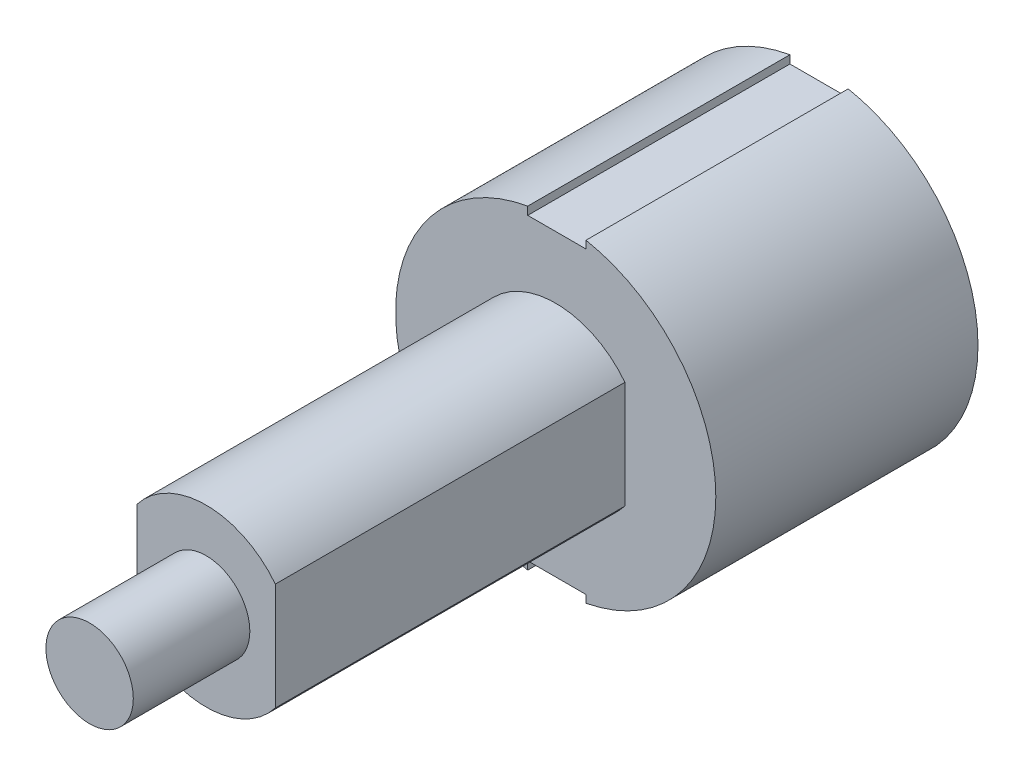
from build123d import *

# Parameters (mm, degrees)
SALIENTE_EXTRUIR4_DEPTH = 14.2875
CROQUIS1_6_R            = 2.38125
SALIENTE_EXTRUIR5_DEPTH = 33.3375
CROQUIS1_7_R            = 2.38125
SALIENTE_EXTRUIR6_DEPTH = 39.6875


with BuildPart() as part:
    # Croquis1 → Saliente-Extruir4 (new body)
    with BuildSketch(Plane.XY):
        with BuildLine():
            Line((-1.524, 8.152705854), (-1.524, 8.590768534))
            ThreePointArc((-1.524, 8.590768534), (-8.7249, 0), (-1.524, -8.590768534))
            Line((-1.524, -8.590768534), (-1.524, -8.152705854))
            Line((-1.524, -8.152705854), (1.651, -8.152705854))
            Line((1.651, -8.152705854), (1.651, -8.567267885))
            ThreePointArc((1.651, -8.567267885), (8.7249, 0), (1.651, 8.567267885))
            Line((1.651, 8.567267885), (1.651, 8.152705854))
            Line((1.651, 8.152705854), (-1.524, 8.152705854))
        make_face()
        with BuildLine():
            ThreePointArc((3.77063, -2.921710837), (0, -4.77012), (-3.77063, -2.921710837))
            Line((-3.77063, -2.921710837), (-3.77063, 2.921710837))
            ThreePointArc((-3.77063, 2.921710837), (0, 4.77012), (3.77063, 2.921710837))
            Line((3.77063, 2.921710837), (3.77063, -2.921710837))
        make_face(mode=Mode.SUBTRACT)
    extrude(amount=SALIENTE_EXTRUIR4_DEPTH)

    # Croquis1_6 → Saliente-Extruir5 (add)
    with BuildSketch(Plane.XY):
        with BuildLine():
            Line((-3.77063, 2.921710837), (-3.77063, -2.921710837))
            ThreePointArc((-3.77063, -2.921710837), (0, -4.77012), (3.77063, -2.921710837))
            Line((3.77063, -2.921710837), (3.77063, 2.921710837))
            ThreePointArc((3.77063, 2.921710837), (0, 4.77012), (-3.77063, 2.921710837))
        make_face()
        Circle(CROQUIS1_6_R, mode=Mode.SUBTRACT)
    extrude(amount=SALIENTE_EXTRUIR5_DEPTH)

    # Croquis1_7 → Saliente-Extruir6 (add)
    with BuildSketch(Plane.XY):
        Circle(CROQUIS1_7_R)
    extrude(amount=SALIENTE_EXTRUIR6_DEPTH)


solid = part.part
